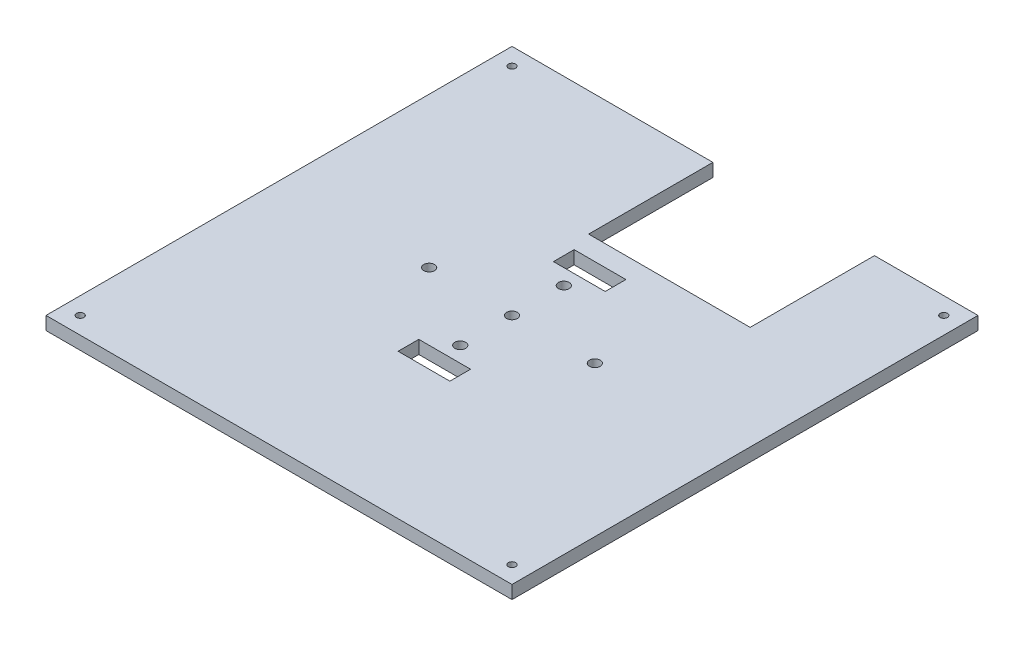
from build123d import *

# Parameters (mm, degrees)
SKETCH1_W           = 225
SKETCH1_H           = 225
BOSS_EXTRUDE1_DEPTH = 6.35
SKETCH2_R           = 1.75
CUT_EXTRUDE1_DEPTH  = 7.35
SKETCH3_R           = 2.6
SKETCH3_W           = 25
SKETCH3_H           = 10
SKETCH3_W_2         = 78
SKETCH3_H_2         = 60
CUT_EXTRUDE2_DEPTH  = 6.35


with BuildPart() as part:
    # Sketch1 → Boss-Extrude1 (new body)
    with BuildSketch(Plane(origin=(0, 0, 0), x_dir=(1, 0, 0), z_dir=(0, 1, 0))):
        with Locations((112.5, 112.5)):
            Rectangle(SKETCH1_W, SKETCH1_H)
    extrude(amount=BOSS_EXTRUDE1_DEPTH)

    # Sketch2 → Cut-Extrude1 (cut, through all)
    with BuildSketch(Plane(origin=(0, 6.35, 0), x_dir=(1, 0, 0), z_dir=(0, 1, 0))):
        with Locations((216.74, 216.74)):
            Circle(SKETCH2_R)
        with Locations((8.26, 216.74)):
            Circle(SKETCH2_R)
        with Locations((216.74, 8.26)):
            Circle(SKETCH2_R)
        with Locations((8.26, 8.26)):
            Circle(SKETCH2_R)
    extrude(amount=-CUT_EXTRUDE1_DEPTH, mode=Mode.SUBTRACT)

    # Sketch3 → Cut-Extrude2 (cut)
    with BuildSketch(Plane(origin=(0, 6.35, 0), x_dir=(1, 0, 0), z_dir=(0, 1, 0))):
        with Locations((152.5, 112.5)):
            Circle(SKETCH3_R)
        with Locations((112.5, 112.5)):
            Circle(SKETCH3_R)
        with Locations((72.5, 112.5)):
            Circle(SKETCH3_R)
        with Locations((112.5, 87.5)):
            Circle(SKETCH3_R)
        with Locations((112.5, 137.5)):
            Circle(SKETCH3_R)
        with Locations((112.5, 75)):
            Rectangle(SKETCH3_W, SKETCH3_H)
        with Locations((136, 195)):
            Rectangle(SKETCH3_W_2, SKETCH3_H_2)
        with Locations((112.5, 150)):
            Rectangle(SKETCH3_W, SKETCH3_H)
    extrude(amount=-CUT_EXTRUDE2_DEPTH, mode=Mode.SUBTRACT)


solid = part.part
